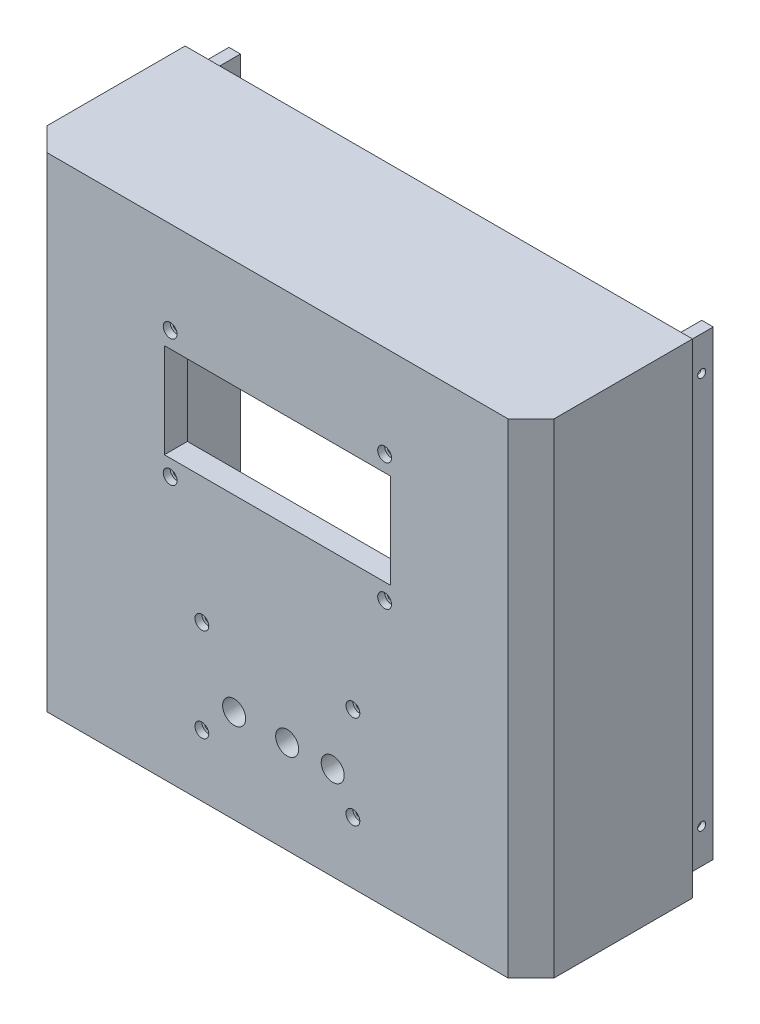
from build123d import *

# Parameters (mm, degrees)
BOSS_EXTRUDE1_DEPTH     = 200
BOSS_EXTRUDE2_DEPTH     = 5
BOSS_EXTRUDE3_START     = 200
BOSS_EXTRUDE3_DEPTH     = 5
BOSS_EXTRUDE5_START     = -70
SKETCH12_W              = 5
SKETCH12_H              = 200
BOSS_EXTRUDE5_DEPTH     = 14
SKETCH13_R              = 1.75
SKETCH13_R_2            = 5
SKETCH13_W              = 98
SKETCH13_H              = 41
CUT_EXTRUDE7_DEPTH      = 1
CUT_EXTRUDE7_DEPTH_BACK = 85
SKETCH15_R              = 3
CUT_EXTRUDE8_DEPTH      = 3
SKETCH16_R              = 1.75
CUT_EXTRUDE9_DEPTH      = 111
CUT_EXTRUDE9_DEPTH_BACK = 111
CUT_EXTRUDE10_START     = -103
CUT_EXTRUDE10_DEPTH     = 3
CUT_EXTRUDE11_START     = 100
CUT_EXTRUDE11_DEPTH     = 3
SKETCH18_R              = 3
CUT_EXTRUDE12_DEPTH     = 3


with BuildPart() as part:
    # Sketch1 → Boss-Extrude1 (new body)
    with BuildSketch(Plane(origin=(0, 0, 0), x_dir=(1, 0, 0), z_dir=(0, 1, 0))):
        Polygon((0, 0), (100, 0), (110, 10), (110, 70), (100, 70), (100, 10), (0, 10), align=None)
    boss_extrude1 = extrude(amount=BOSS_EXTRUDE1_DEPTH)

    # Mirror1: Boss-Extrude1 across plane
    add(boss_extrude1.mirror(Plane(origin=(0, 0, 0), x_dir=(0, 0, 1), z_dir=(1, 0, 0))))

    # Sketch6 → Boss-Extrude2 (add)
    with BuildSketch(Plane(origin=(0, 0, 0), x_dir=(1, 0, 0), z_dir=(0, 1, 0))):
        Polygon((110, 70), (-110, 70), (-110, 10), (-100, 0), (100, 0), (110, 10), align=None)
    extrude(amount=-BOSS_EXTRUDE2_DEPTH)

    # Sketch6_2 → Boss-Extrude3 (add)
    with BuildSketch(Plane(origin=(0, 0, 0), x_dir=(1, 0, 0), z_dir=(0, 1, 0)).offset(BOSS_EXTRUDE3_START)):
        Polygon((110, 70), (-110, 70), (-110, 10), (-100, 0), (100, 0), (110, 10), align=None)
    extrude(amount=BOSS_EXTRUDE3_DEPTH)

    # Sketch12 → Boss-Extrude5 (add)
    with BuildSketch(Plane.XY.offset(BOSS_EXTRUDE5_START)):
        with Locations((102.5, 100)):
            Rectangle(SKETCH12_W, SKETCH12_H)
        with Locations((-102.5, 100)):
            Rectangle(SKETCH12_W, SKETCH12_H)
    extrude(amount=-BOSS_EXTRUDE5_DEPTH)

    # Sketch13 → Cut-Extrude7 (cut, two sides)
    with BuildSketch(Plane.XY) as cut_extrude7_sk:
        with Locations((-46.5, 165)):
            Circle(SKETCH13_R)
        with Locations((46.5, 165)):
            Circle(SKETCH13_R)
        with Locations((46.5, 110)):
            Circle(SKETCH13_R)
        with Locations((-46.5, 110)):
            Circle(SKETCH13_R)
        with Locations((32.75, 62.246184667)):
            Circle(SKETCH13_R)
        with Locations((-32.75, 62.246184667)):
            Circle(SKETCH13_R)
        with Locations((32.75, 21.746184667)):
            Circle(SKETCH13_R)
        with Locations((-32.75, 21.746184667)):
            Circle(SKETCH13_R)
        with Locations((24, 35.496184667)):
            Circle(SKETCH13_R_2)
        with Locations((-18.75, 35.496184667)):
            Circle(SKETCH13_R_2)
        with Locations((4.25, 35.496184667)):
            Circle(SKETCH13_R_2)
        with Locations((0, 137.5)):
            Rectangle(SKETCH13_W, SKETCH13_H)
    extrude(amount=CUT_EXTRUDE7_DEPTH, mode=Mode.SUBTRACT)
    extrude(cut_extrude7_sk.sketch, amount=-CUT_EXTRUDE7_DEPTH_BACK, mode=Mode.SUBTRACT)

    # Sketch15 → Cut-Extrude8 (cut)
    with BuildSketch(Plane.XY):
        with Locations((-46.5, 165)):
            Circle(SKETCH15_R)
        with Locations((46.5, 165)):
            Circle(SKETCH15_R)
        with Locations((46.5, 110)):
            Circle(SKETCH15_R)
        with Locations((-46.5, 110)):
            Circle(SKETCH15_R)
    extrude(amount=-CUT_EXTRUDE8_DEPTH, mode=Mode.SUBTRACT)

    # Sketch16 → Cut-Extrude9 (cut, two sides)
    with BuildSketch(Plane(origin=(0, 0, 0), x_dir=(0, 0, -1), z_dir=(1, 0, 0))) as cut_extrude9_sk:
        with Locations((79, 185)):
            Circle(SKETCH16_R)
        with Locations((79, 15)):
            Circle(SKETCH16_R)
    extrude(amount=CUT_EXTRUDE9_DEPTH, mode=Mode.SUBTRACT)
    extrude(cut_extrude9_sk.sketch, amount=-CUT_EXTRUDE9_DEPTH_BACK, mode=Mode.SUBTRACT)

    # Sketch17 → Cut-Extrude10 (cut)
    with BuildSketch(Plane(origin=(0, 0, 0), x_dir=(0, 0, -1), z_dir=(1, 0, 0)).offset(CUT_EXTRUDE10_START)):
        Polygon((75.535898385, 185), (77.267949192, 182), (80.732050808, 182), (82.464101615, 185), (80.732050808, 188), (77.267949192, 188), align=None)
        Polygon((75.690677898, 13.976092178), (78.232069134, 11.62208908), (81.541391236, 12.645996901), (82.309322102, 16.023907822), (79.767930866, 18.37791092), (76.458608764, 17.354003099), align=None)
    extrude(amount=CUT_EXTRUDE10_DEPTH, mode=Mode.SUBTRACT)

    # Sketch17_2 → Cut-Extrude11 (cut)
    with BuildSketch(Plane(origin=(0, 0, 0), x_dir=(0, 0, -1), z_dir=(1, 0, 0)).offset(CUT_EXTRUDE11_START)):
        Polygon((75.535898385, 185), (77.267949192, 182), (80.732050808, 182), (82.464101615, 185), (80.732050808, 188), (77.267949192, 188), align=None)
        Polygon((75.690677898, 13.976092178), (78.232069134, 11.62208908), (81.541391236, 12.645996901), (82.309322102, 16.023907822), (79.767930866, 18.37791092), (76.458608764, 17.354003099), align=None)
    extrude(amount=CUT_EXTRUDE11_DEPTH, mode=Mode.SUBTRACT)

    # Sketch18 → Cut-Extrude12 (cut)
    with BuildSketch(Plane.XY):
        with Locations((32.75, 62.246184667)):
            Circle(SKETCH18_R)
        with Locations((-32.75, 62.246184667)):
            Circle(SKETCH18_R)
        with Locations((-32.75, 21.746184667)):
            Circle(SKETCH18_R)
        with Locations((32.75, 21.746184667)):
            Circle(SKETCH18_R)
    extrude(amount=-CUT_EXTRUDE12_DEPTH, mode=Mode.SUBTRACT)


solid = part.part
